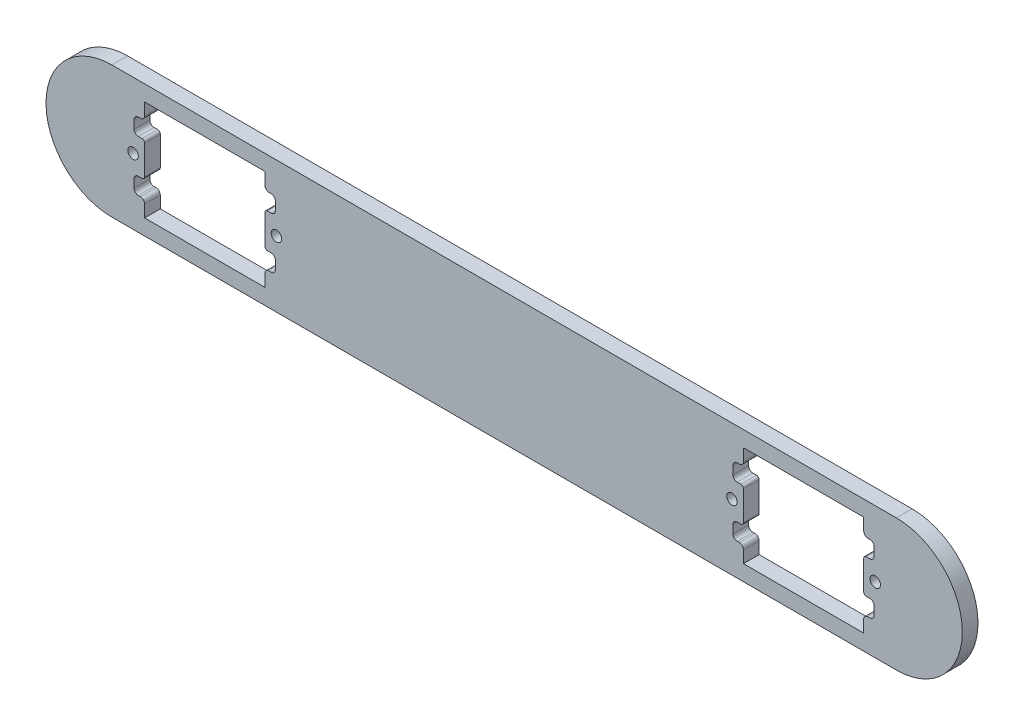
from build123d import *

# Parameters (mm, degrees)
SKETCH_1_R          = 1
SKETCH_1_W          = 23
SKETCH_1_H          = 13
EXTRUDE_1_DEPTH     = 1.5
CUT_EXTRUDE_1_DEPTH = 3
FILLET_1_R          = 0.5


with BuildPart() as part:
    # 草图1 → 凸台-拉伸1 (new body, symmetric)
    with BuildSketch(Plane.XY):
        with BuildLine():
            Line((-75, 12.6), (75, 12.6))
            ThreePointArc((75, 12.6), (87.6, 0), (75, -12.6))
            Line((75, -12.6), (-75, -12.6))
            ThreePointArc((-75, -12.6), (-87.6, 0), (-75, 12.6))
        make_face()
        with Locations((-43.55, 0)):
            Circle(SKETCH_1_R, mode=Mode.SUBTRACT)
        with Locations((-70.95, 0)):
            Circle(SKETCH_1_R, mode=Mode.SUBTRACT)
        with Locations((70.95, 0)):
            Circle(SKETCH_1_R, mode=Mode.SUBTRACT)
        with Locations((43.55, 0)):
            Circle(SKETCH_1_R, mode=Mode.SUBTRACT)
        with Locations((-57.25, 0)):
            Rectangle(SKETCH_1_W, SKETCH_1_H, mode=Mode.SUBTRACT)
        with Locations((57.25, 0)):
            Rectangle(SKETCH_1_W, SKETCH_1_H, mode=Mode.SUBTRACT)
    extrude(amount=EXTRUDE_1_DEPTH, both=True)

    # 草图2 → 切除-拉伸1 (cut)
    with BuildSketch(Plane.XY.offset(1.5)):
        with BuildLine():
            Line((44.95, 6.5), (44.55, 6.5))
            ThreePointArc((44.55, 6.5), (43.984314575, 6.265685425), (43.75, 5.7))
            Line((43.75, 5.7), (43.75, 4.1))
            ThreePointArc((43.75, 4.1), (43.984314575, 3.534314575), (44.55, 3.3))
            Line((44.55, 3.3), (45.75, 3.3))
            Line((45.75, 3.3), (45.75, 6.5))
            Line((45.75, 6.5), (68.75, 6.5))
            Line((68.75, 6.5), (68.75, 3.3))
            Line((68.75, 3.3), (69.95, 3.3))
            ThreePointArc((69.95, 3.3), (70.515685425, 3.534314575), (70.75, 4.1))
            Line((70.75, 4.1), (70.75, 5.7))
            ThreePointArc((70.75, 5.7), (70.515685425, 6.265685425), (69.95, 6.5))
            Line((69.95, 6.5), (69.55, 6.5))
            ThreePointArc((69.55, 6.5), (68.984314575, 6.734314575), (68.75, 7.3))
            Line((68.75, 7.3), (68.75, 9.6))
            Line((68.75, 9.6), (45.75, 9.6))
            Line((45.75, 9.6), (45.75, 7.3))
            ThreePointArc((45.75, 7.3), (45.515685425, 6.734314575), (44.95, 6.5))
        make_face()
        with BuildLine():
            Line((44.55, -3.3), (45.75, -3.3))
            Line((45.75, -3.3), (45.75, -6.5))
            Line((45.75, -6.5), (68.75, -6.5))
            Line((68.75, -6.5), (68.75, -3.3))
            Line((68.75, -3.3), (69.95, -3.3))
            ThreePointArc((69.95, -3.3), (70.515685425, -3.534314575), (70.75, -4.1))
            Line((70.75, -4.1), (70.75, -5.7))
            ThreePointArc((70.75, -5.7), (70.515685425, -6.265685425), (69.95, -6.5))
            Line((69.95, -6.5), (69.55, -6.5))
            ThreePointArc((69.55, -6.5), (68.984314575, -6.734314575), (68.75, -7.3))
            Line((68.75, -7.3), (68.75, -9.6))
            Line((68.75, -9.6), (45.75, -9.6))
            Line((45.75, -9.6), (45.75, -7.3))
            ThreePointArc((45.75, -7.3), (45.515685425, -6.734314575), (44.95, -6.5))
            Line((44.95, -6.5), (44.55, -6.5))
            ThreePointArc((44.55, -6.5), (43.984314575, -6.265685425), (43.75, -5.7))
            Line((43.75, -5.7), (43.75, -4.1))
            ThreePointArc((43.75, -4.1), (43.984314575, -3.534314575), (44.55, -3.3))
        make_face()
        with BuildLine():
            Line((-45.75, 3.3), (-45.75, 6.5))
            Line((-45.75, 6.5), (-68.75, 6.5))
            Line((-68.75, 6.5), (-68.75, 3.3))
            Line((-68.75, 3.3), (-69.95, 3.3))
            ThreePointArc((-69.95, 3.3), (-70.515685425, 3.534314575), (-70.75, 4.1))
            Line((-70.75, 4.1), (-70.75, 5.7))
            ThreePointArc((-70.75, 5.7), (-70.515685425, 6.265685425), (-69.95, 6.5))
            Line((-69.95, 6.5), (-69.55, 6.5))
            ThreePointArc((-69.55, 6.5), (-68.984314575, 6.734314575), (-68.75, 7.3))
            Line((-68.75, 7.3), (-68.75, 9.6))
            Line((-68.75, 9.6), (-45.75, 9.6))
            Line((-45.75, 9.6), (-45.75, 7.3))
            ThreePointArc((-45.75, 7.3), (-45.515685425, 6.734314575), (-44.95, 6.5))
            Line((-44.95, 6.5), (-44.55, 6.5))
            ThreePointArc((-44.55, 6.5), (-43.984314575, 6.265685425), (-43.75, 5.7))
            Line((-43.75, 5.7), (-43.75, 4.1))
            ThreePointArc((-43.75, 4.1), (-43.984314575, 3.534314575), (-44.55, 3.3))
            Line((-44.55, 3.3), (-45.75, 3.3))
        make_face()
        with BuildLine():
            Line((-45.75, -7.3), (-45.75, -9.6))
            Line((-45.75, -9.6), (-68.75, -9.6))
            Line((-68.75, -9.6), (-68.75, -7.3))
            ThreePointArc((-68.75, -7.3), (-68.984314575, -6.734314575), (-69.55, -6.5))
            Line((-69.55, -6.5), (-69.95, -6.5))
            ThreePointArc((-69.95, -6.5), (-70.515685425, -6.265685425), (-70.75, -5.7))
            Line((-70.75, -5.7), (-70.75, -4.1))
            ThreePointArc((-70.75, -4.1), (-70.515685425, -3.534314575), (-69.95, -3.3))
            Line((-69.95, -3.3), (-68.75, -3.3))
            Line((-68.75, -3.3), (-68.75, -6.5))
            Line((-68.75, -6.5), (-45.75, -6.5))
            Line((-45.75, -6.5), (-45.75, -3.3))
            Line((-45.75, -3.3), (-44.55, -3.3))
            ThreePointArc((-44.55, -3.3), (-43.984314575, -3.534314575), (-43.75, -4.1))
            Line((-43.75, -4.1), (-43.75, -5.7))
            ThreePointArc((-43.75, -5.7), (-43.984314575, -6.265685425), (-44.55, -6.5))
            Line((-44.55, -6.5), (-44.95, -6.5))
            ThreePointArc((-44.95, -6.5), (-45.515685425, -6.734314575), (-45.75, -7.3))
        make_face()
    extrude(amount=-CUT_EXTRUDE_1_DEPTH, mode=Mode.SUBTRACT)

    # 圆角1
    fillet_1_edges = [part.edges().sort_by_distance(p)[0] for p in [
        (45.75, -3.3, 0),
        (68.75, -3.3, 0),
        (-45.75, 3.3, 0),
        (-68.75, 3.3, 0),
        (-68.75, -3.3, 0),
        (-45.75, -3.3, 0),
        (45.75, 3.3, 0),
        (68.75, 3.3, 0),
    ]]
    fillet(fillet_1_edges, radius=FILLET_1_R)


solid = part.part
